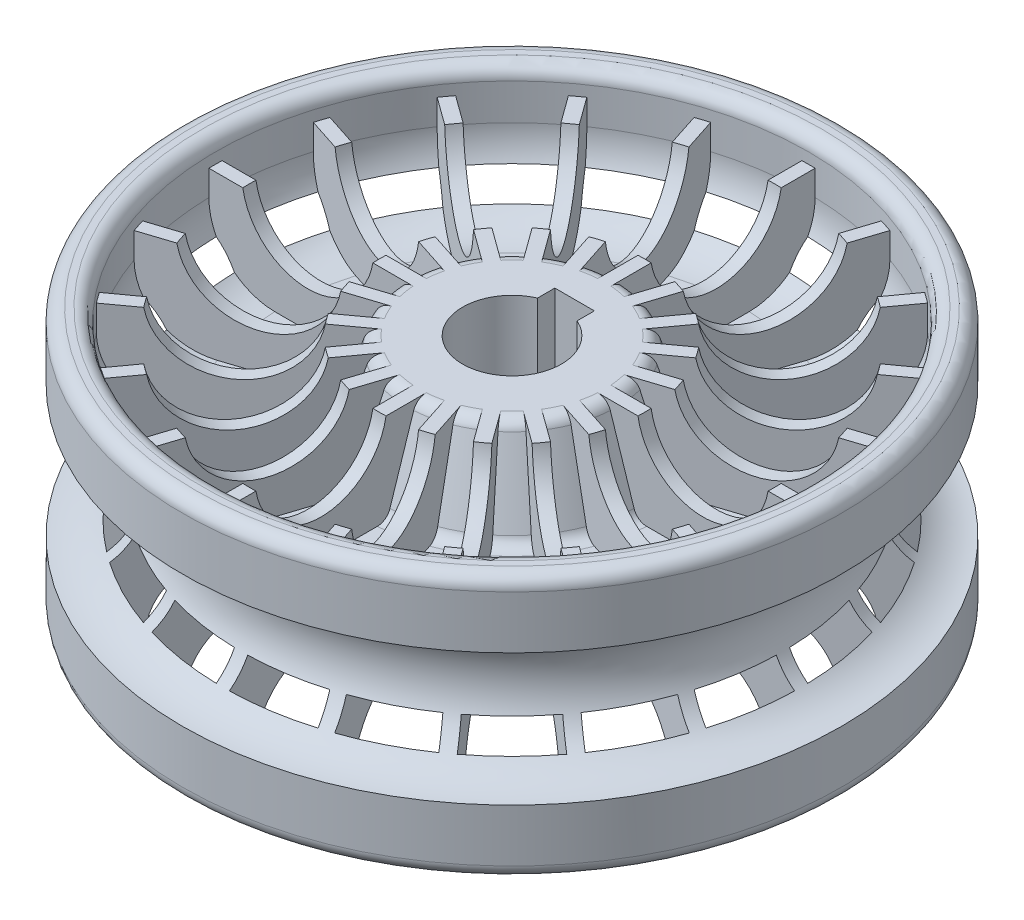
from build123d import *

# Parameters (mm, degrees)
FILLET1_R                    = 1
FILLET2_R                    = 5
RIB5_REACH                   = 41.753
SKETCH2_WALLS_W              = 1
SKETCH2_WALLS_H              = 88.280008708
CIRPATTERN1_COUNT            = 20
CIRPATTERN1_COPY_1_REACH     = 41.753
CIRPATTERN1_COPY_1_SKETCH_W  = 1
CIRPATTERN1_COPY_1_SKETCH_H  = 88.280008708
CIRPATTERN1_COPY_2_REACH     = 41.753
CIRPATTERN1_COPY_2_SKETCH_W  = 1
CIRPATTERN1_COPY_2_SKETCH_H  = 88.280008708
CIRPATTERN1_COPY_3_REACH     = 41.753
CIRPATTERN1_COPY_3_SKETCH_W  = 1
CIRPATTERN1_COPY_3_SKETCH_H  = 88.280008708
CIRPATTERN1_COPY_4_REACH     = 41.753
CIRPATTERN1_COPY_4_SKETCH_W  = 1
CIRPATTERN1_COPY_4_SKETCH_H  = 88.280008708
CIRPATTERN1_COPY_5_REACH     = 41.753
CIRPATTERN1_COPY_5_SKETCH_W  = 1
CIRPATTERN1_COPY_5_SKETCH_H  = 88.280008708
CIRPATTERN1_COPY_6_REACH     = 41.753
CIRPATTERN1_COPY_6_SKETCH_W  = 1
CIRPATTERN1_COPY_6_SKETCH_H  = 88.280008708
CIRPATTERN1_COPY_7_REACH     = 41.753
CIRPATTERN1_COPY_7_SKETCH_W  = 1
CIRPATTERN1_COPY_7_SKETCH_H  = 88.280008708
CIRPATTERN1_COPY_8_REACH     = 41.753
CIRPATTERN1_COPY_8_SKETCH_W  = 1
CIRPATTERN1_COPY_8_SKETCH_H  = 88.280008708
CIRPATTERN1_COPY_9_REACH     = 41.753
CIRPATTERN1_COPY_9_SKETCH_W  = 1
CIRPATTERN1_COPY_9_SKETCH_H  = 88.280008708
CIRPATTERN1_COPY_10_REACH    = 41.753
CIRPATTERN1_COPY_10_SKETCH_W = 1
CIRPATTERN1_COPY_10_SKETCH_H = 88.280008708
CIRPATTERN1_COPY_11_REACH    = 41.753
CIRPATTERN1_COPY_11_SKETCH_W = 1
CIRPATTERN1_COPY_11_SKETCH_H = 88.280008708
CIRPATTERN1_COPY_12_REACH    = 41.753
CIRPATTERN1_COPY_12_SKETCH_W = 1
CIRPATTERN1_COPY_12_SKETCH_H = 88.280008708
CIRPATTERN1_COPY_13_REACH    = 41.753
CIRPATTERN1_COPY_13_SKETCH_W = 1
CIRPATTERN1_COPY_13_SKETCH_H = 88.280008708
CIRPATTERN1_COPY_14_REACH    = 41.753
CIRPATTERN1_COPY_14_SKETCH_W = 1
CIRPATTERN1_COPY_14_SKETCH_H = 88.280008708
CIRPATTERN1_COPY_15_REACH    = 41.753
CIRPATTERN1_COPY_15_SKETCH_W = 1
CIRPATTERN1_COPY_15_SKETCH_H = 88.280008708
CIRPATTERN1_COPY_16_REACH    = 41.753
CIRPATTERN1_COPY_16_SKETCH_W = 1
CIRPATTERN1_COPY_16_SKETCH_H = 88.280008708
CIRPATTERN1_COPY_17_REACH    = 41.753
CIRPATTERN1_COPY_17_SKETCH_W = 1
CIRPATTERN1_COPY_17_SKETCH_H = 88.280008708
CIRPATTERN1_COPY_18_REACH    = 41.753
CIRPATTERN1_COPY_18_SKETCH_W = 1
CIRPATTERN1_COPY_18_SKETCH_H = 88.280008708
CIRPATTERN1_COPY_19_REACH    = 41.753
CIRPATTERN1_COPY_19_SKETCH_W = 1
CIRPATTERN1_COPY_19_SKETCH_H = 88.280008708
SKETCH3_R                    = 5
SKETCH4_W                    = 3
SKETCH4_H                    = 2
CUT_EXTRUDE2_DEPTH           = 40.753275681
CUT_EXTRUDE2_DEPTH_BACK      = 40.753275681


with BuildPart() as part:
    # Sketch1 → Revolve1 (revolve)
    with BuildSketch(Plane.XY, mode=Mode.PRIVATE) as revolve1_sk:
        Polygon((-3.75, -8.174787959), (-3.75, 8.174787959), (-7.75, 8.174787959), (-10, 1.25), (-22.5, 1.25), (-22.5, 10), (-25, 10), (-25, -10), (-22.5, -10), (-22.5, -1.25), (-10, -1.25), (-7.75, -8.174787959), align=None)
    revolve(revolve1_sk.sketch.rotate(Axis((0, 0, 0), (0, 1, 0)), 270), axis=Axis((0, 0, 0), (0, 1, 0)))

    # Fillet1
    fillet1_edges = [part.edges().sort_by_distance(p)[0] for p in [
        (0, -10, 22.5),
        (0, -10, 25),
        (0, 10, 25),
        (0, 10, 22.5),
        (0, 1.25, 10),
        (0, 8.174787959, 7.75),
        (0, -8.174787959, 7.75),
        (0, -1.25, 10),
    ]]
    fillet(fillet1_edges, radius=FILLET1_R)

    # Fillet2
    fillet2_edges = [part.edges().sort_by_distance(p)[0] for p in [
        (0, 1.25, 22.5),
        (0, -1.25, 22.5),
    ]]
    fillet(fillet2_edges, radius=FILLET2_R)

    # Sketch2 walls → Rib5 (add, up to next)
    with BuildSketch(Plane(origin=(0, 8.174787959, 0), x_dir=(1, 0, 0), z_dir=(0, 1, 0)), mode=Mode.PRIVATE) as rib5_sk1:
        with Locations((0, 14.113271264)):
            Rectangle(SKETCH2_WALLS_W, SKETCH2_WALLS_H)
    rib5_tool1 = extrude(rib5_sk1.sketch, amount=-RIB5_REACH, mode=Mode.PRIVATE) - part.part
    rib5 = rib5_tool1.solids().sort_by_distance((0, 8.174787959, -14.113271264))[0]
    add(rib5)

    # Mirror1: Rib5 across plane
    add(rib5.mirror(Plane.ZX))

    # CirPattern1: Rib5 ×20 about axis
    cirpattern1_axis = Axis((0, 0, 0), (0, 1, 0))
    for i in range(1, CIRPATTERN1_COUNT):
        add(rib5.rotate(cirpattern1_axis, i * 360 / CIRPATTERN1_COUNT))

    # CirPattern1 copy 1 sketch → CirPattern1 copy 1 (add, up to next)
    with BuildSketch(Plane(origin=(0, -8.174787959, 0), x_dir=(0.9510565162951535, 0, -0.3090169943749474), z_dir=(0, -1, 0)), mode=Mode.PRIVATE) as cirpattern1_copy_1_sk1:
        with Locations((0, -14.113271264)):
            Rectangle(CIRPATTERN1_COPY_1_SKETCH_W, CIRPATTERN1_COPY_1_SKETCH_H)
    cirpattern1_copy_1_tool1 = extrude(cirpattern1_copy_1_sk1.sketch, amount=-CIRPATTERN1_COPY_1_REACH, mode=Mode.PRIVATE) - part.part
    add(cirpattern1_copy_1_tool1.solids().sort_by_distance((-4.361240667, -8.174787959, -13.422518602))[0])

    # CirPattern1 copy 2 sketch → CirPattern1 copy 2 (add, up to next)
    with BuildSketch(Plane(origin=(0, -8.174787959, 0), x_dir=(0.8090169943749475, 0, -0.5877852522924731), z_dir=(0, -1, 0)), mode=Mode.PRIVATE) as cirpattern1_copy_2_sk1:
        with Locations((0, -14.113271264)):
            Rectangle(CIRPATTERN1_COPY_2_SKETCH_W, CIRPATTERN1_COPY_2_SKETCH_H)
    cirpattern1_copy_2_tool1 = extrude(cirpattern1_copy_2_sk1.sketch, amount=-CIRPATTERN1_COPY_2_REACH, mode=Mode.PRIVATE) - part.part
    add(cirpattern1_copy_2_tool1.solids().sort_by_distance((-8.295572711, -8.174787959, -11.417876299))[0])

    # CirPattern1 copy 3 sketch → CirPattern1 copy 3 (add, up to next)
    with BuildSketch(Plane(origin=(0, -8.174787959, 0), x_dir=(0.5877852522924731, 0, -0.8090169943749475), z_dir=(0, -1, 0)), mode=Mode.PRIVATE) as cirpattern1_copy_3_sk1:
        with Locations((0, -14.113271264)):
            Rectangle(CIRPATTERN1_COPY_3_SKETCH_W, CIRPATTERN1_COPY_3_SKETCH_H)
    cirpattern1_copy_3_tool1 = extrude(cirpattern1_copy_3_sk1.sketch, amount=-CIRPATTERN1_COPY_3_REACH, mode=Mode.PRIVATE) - part.part
    add(cirpattern1_copy_3_tool1.solids().sort_by_distance((-11.417876299, -8.174787959, -8.295572711))[0])

    # CirPattern1 copy 4 sketch → CirPattern1 copy 4 (add, up to next)
    with BuildSketch(Plane(origin=(0, -8.174787959, 0), x_dir=(0.30901699437494745, 0, -0.9510565162951535), z_dir=(0, -1, 0)), mode=Mode.PRIVATE) as cirpattern1_copy_4_sk1:
        with Locations((0, -14.113271264)):
            Rectangle(CIRPATTERN1_COPY_4_SKETCH_W, CIRPATTERN1_COPY_4_SKETCH_H)
    cirpattern1_copy_4_tool1 = extrude(cirpattern1_copy_4_sk1.sketch, amount=-CIRPATTERN1_COPY_4_REACH, mode=Mode.PRIVATE) - part.part
    add(cirpattern1_copy_4_tool1.solids().sort_by_distance((-13.422518602, -8.174787959, -4.361240667))[0])

    # CirPattern1 copy 5 sketch → CirPattern1 copy 5 (add, up to next)
    with BuildSketch(Plane(origin=(0, -8.174787959, 0), x_dir=(0, 0, -1), z_dir=(0, -1, 0)), mode=Mode.PRIVATE) as cirpattern1_copy_5_sk1:
        with Locations((0, -14.113271264)):
            Rectangle(CIRPATTERN1_COPY_5_SKETCH_W, CIRPATTERN1_COPY_5_SKETCH_H)
    cirpattern1_copy_5_tool1 = extrude(cirpattern1_copy_5_sk1.sketch, amount=-CIRPATTERN1_COPY_5_REACH, mode=Mode.PRIVATE) - part.part
    add(cirpattern1_copy_5_tool1.solids().sort_by_distance((-14.113271264, -8.174787959, 0))[0])

    # CirPattern1 copy 6 sketch → CirPattern1 copy 6 (add, up to next)
    with BuildSketch(Plane(origin=(0, -8.174787959, 0), x_dir=(-0.30901699437494734, 0, -0.9510565162951536), z_dir=(0, -1, 0)), mode=Mode.PRIVATE) as cirpattern1_copy_6_sk1:
        with Locations((0, -14.113271264)):
            Rectangle(CIRPATTERN1_COPY_6_SKETCH_W, CIRPATTERN1_COPY_6_SKETCH_H)
    cirpattern1_copy_6_tool1 = extrude(cirpattern1_copy_6_sk1.sketch, amount=-CIRPATTERN1_COPY_6_REACH, mode=Mode.PRIVATE) - part.part
    add(cirpattern1_copy_6_tool1.solids().sort_by_distance((-13.422518602, -8.174787959, 4.361240667))[0])

    # CirPattern1 copy 7 sketch → CirPattern1 copy 7 (add, up to next)
    with BuildSketch(Plane(origin=(0, -8.174787959, 0), x_dir=(-0.587785252292473, 0, -0.8090169943749475), z_dir=(0, -1, 0)), mode=Mode.PRIVATE) as cirpattern1_copy_7_sk1:
        with Locations((0, -14.113271264)):
            Rectangle(CIRPATTERN1_COPY_7_SKETCH_W, CIRPATTERN1_COPY_7_SKETCH_H)
    cirpattern1_copy_7_tool1 = extrude(cirpattern1_copy_7_sk1.sketch, amount=-CIRPATTERN1_COPY_7_REACH, mode=Mode.PRIVATE) - part.part
    add(cirpattern1_copy_7_tool1.solids().sort_by_distance((-11.417876299, -8.174787959, 8.295572711))[0])

    # CirPattern1 copy 8 sketch → CirPattern1 copy 8 (add, up to next)
    with BuildSketch(Plane(origin=(0, -8.174787959, 0), x_dir=(-0.8090169943749473, 0, -0.5877852522924732), z_dir=(0, -1, 0)), mode=Mode.PRIVATE) as cirpattern1_copy_8_sk1:
        with Locations((0, -14.113271264)):
            Rectangle(CIRPATTERN1_COPY_8_SKETCH_W, CIRPATTERN1_COPY_8_SKETCH_H)
    cirpattern1_copy_8_tool1 = extrude(cirpattern1_copy_8_sk1.sketch, amount=-CIRPATTERN1_COPY_8_REACH, mode=Mode.PRIVATE) - part.part
    add(cirpattern1_copy_8_tool1.solids().sort_by_distance((-8.295572711, -8.174787959, 11.417876299))[0])

    # CirPattern1 copy 9 sketch → CirPattern1 copy 9 (add, up to next)
    with BuildSketch(Plane(origin=(0, -8.174787959, 0), x_dir=(-0.9510565162951535, 0, -0.3090169943749475), z_dir=(0, -1, 0)), mode=Mode.PRIVATE) as cirpattern1_copy_9_sk1:
        with Locations((0, -14.113271264)):
            Rectangle(CIRPATTERN1_COPY_9_SKETCH_W, CIRPATTERN1_COPY_9_SKETCH_H)
    cirpattern1_copy_9_tool1 = extrude(cirpattern1_copy_9_sk1.sketch, amount=-CIRPATTERN1_COPY_9_REACH, mode=Mode.PRIVATE) - part.part
    add(cirpattern1_copy_9_tool1.solids().sort_by_distance((-4.361240667, -8.174787959, 13.422518602))[0])

    # CirPattern1 copy 10 sketch → CirPattern1 copy 10 (add, up to next)
    with BuildSketch(Plane(origin=(0, -8.174787959, 0), x_dir=(-1, 0, 0), z_dir=(0, -1, 0)), mode=Mode.PRIVATE) as cirpattern1_copy_10_sk1:
        with Locations((0, -14.113271264)):
            Rectangle(CIRPATTERN1_COPY_10_SKETCH_W, CIRPATTERN1_COPY_10_SKETCH_H)
    cirpattern1_copy_10_tool1 = extrude(cirpattern1_copy_10_sk1.sketch, amount=-CIRPATTERN1_COPY_10_REACH, mode=Mode.PRIVATE) - part.part
    add(cirpattern1_copy_10_tool1.solids().sort_by_distance((0, -8.174787959, 14.113271264))[0])

    # CirPattern1 copy 11 sketch → CirPattern1 copy 11 (add, up to next)
    with BuildSketch(Plane(origin=(0, -8.174787959, 0), x_dir=(-0.9510565162951536, 0, 0.3090169943749473), z_dir=(0, -1, 0)), mode=Mode.PRIVATE) as cirpattern1_copy_11_sk1:
        with Locations((0, -14.113271264)):
            Rectangle(CIRPATTERN1_COPY_11_SKETCH_W, CIRPATTERN1_COPY_11_SKETCH_H)
    cirpattern1_copy_11_tool1 = extrude(cirpattern1_copy_11_sk1.sketch, amount=-CIRPATTERN1_COPY_11_REACH, mode=Mode.PRIVATE) - part.part
    add(cirpattern1_copy_11_tool1.solids().sort_by_distance((4.361240667, -8.174787959, 13.422518602))[0])

    # CirPattern1 copy 12 sketch → CirPattern1 copy 12 (add, up to next)
    with BuildSketch(Plane(origin=(0, -8.174787959, 0), x_dir=(-0.8090169943749476, 0, 0.587785252292473), z_dir=(0, -1, 0)), mode=Mode.PRIVATE) as cirpattern1_copy_12_sk1:
        with Locations((0, -14.113271264)):
            Rectangle(CIRPATTERN1_COPY_12_SKETCH_W, CIRPATTERN1_COPY_12_SKETCH_H)
    cirpattern1_copy_12_tool1 = extrude(cirpattern1_copy_12_sk1.sketch, amount=-CIRPATTERN1_COPY_12_REACH, mode=Mode.PRIVATE) - part.part
    add(cirpattern1_copy_12_tool1.solids().sort_by_distance((8.295572711, -8.174787959, 11.417876299))[0])

    # CirPattern1 copy 13 sketch → CirPattern1 copy 13 (add, up to next)
    with BuildSketch(Plane(origin=(0, -8.174787959, 0), x_dir=(-0.5877852522924732, 0, 0.8090169943749473), z_dir=(0, -1, 0)), mode=Mode.PRIVATE) as cirpattern1_copy_13_sk1:
        with Locations((0, -14.113271264)):
            Rectangle(CIRPATTERN1_COPY_13_SKETCH_W, CIRPATTERN1_COPY_13_SKETCH_H)
    cirpattern1_copy_13_tool1 = extrude(cirpattern1_copy_13_sk1.sketch, amount=-CIRPATTERN1_COPY_13_REACH, mode=Mode.PRIVATE) - part.part
    add(cirpattern1_copy_13_tool1.solids().sort_by_distance((11.417876299, -8.174787959, 8.295572711))[0])

    # CirPattern1 copy 14 sketch → CirPattern1 copy 14 (add, up to next)
    with BuildSketch(Plane(origin=(0, -8.174787959, 0), x_dir=(-0.30901699437494756, 0, 0.9510565162951535), z_dir=(0, -1, 0)), mode=Mode.PRIVATE) as cirpattern1_copy_14_sk1:
        with Locations((0, -14.113271264)):
            Rectangle(CIRPATTERN1_COPY_14_SKETCH_W, CIRPATTERN1_COPY_14_SKETCH_H)
    cirpattern1_copy_14_tool1 = extrude(cirpattern1_copy_14_sk1.sketch, amount=-CIRPATTERN1_COPY_14_REACH, mode=Mode.PRIVATE) - part.part
    add(cirpattern1_copy_14_tool1.solids().sort_by_distance((13.422518602, -8.174787959, 4.361240667))[0])

    # CirPattern1 copy 15 sketch → CirPattern1 copy 15 (add, up to next)
    with BuildSketch(Plane(origin=(0, -8.174787959, 0), x_dir=(0, 0, 1), z_dir=(0, -1, 0)), mode=Mode.PRIVATE) as cirpattern1_copy_15_sk1:
        with Locations((0, -14.113271264)):
            Rectangle(CIRPATTERN1_COPY_15_SKETCH_W, CIRPATTERN1_COPY_15_SKETCH_H)
    cirpattern1_copy_15_tool1 = extrude(cirpattern1_copy_15_sk1.sketch, amount=-CIRPATTERN1_COPY_15_REACH, mode=Mode.PRIVATE) - part.part
    add(cirpattern1_copy_15_tool1.solids().sort_by_distance((14.113271264, -8.174787959, 0))[0])

    # CirPattern1 copy 16 sketch → CirPattern1 copy 16 (add, up to next)
    with BuildSketch(Plane(origin=(0, -8.174787959, 0), x_dir=(0.30901699437494723, 0, 0.9510565162951536), z_dir=(0, -1, 0)), mode=Mode.PRIVATE) as cirpattern1_copy_16_sk1:
        with Locations((0, -14.113271264)):
            Rectangle(CIRPATTERN1_COPY_16_SKETCH_W, CIRPATTERN1_COPY_16_SKETCH_H)
    cirpattern1_copy_16_tool1 = extrude(cirpattern1_copy_16_sk1.sketch, amount=-CIRPATTERN1_COPY_16_REACH, mode=Mode.PRIVATE) - part.part
    add(cirpattern1_copy_16_tool1.solids().sort_by_distance((13.422518602, -8.174787959, -4.361240667))[0])

    # CirPattern1 copy 17 sketch → CirPattern1 copy 17 (add, up to next)
    with BuildSketch(Plane(origin=(0, -8.174787959, 0), x_dir=(0.5877852522924729, 0, 0.8090169943749476), z_dir=(0, -1, 0)), mode=Mode.PRIVATE) as cirpattern1_copy_17_sk1:
        with Locations((0, -14.113271264)):
            Rectangle(CIRPATTERN1_COPY_17_SKETCH_W, CIRPATTERN1_COPY_17_SKETCH_H)
    cirpattern1_copy_17_tool1 = extrude(cirpattern1_copy_17_sk1.sketch, amount=-CIRPATTERN1_COPY_17_REACH, mode=Mode.PRIVATE) - part.part
    add(cirpattern1_copy_17_tool1.solids().sort_by_distance((11.417876299, -8.174787959, -8.295572711))[0])

    # CirPattern1 copy 18 sketch → CirPattern1 copy 18 (add, up to next)
    with BuildSketch(Plane(origin=(0, -8.174787959, 0), x_dir=(0.8090169943749473, 0, 0.5877852522924734), z_dir=(0, -1, 0)), mode=Mode.PRIVATE) as cirpattern1_copy_18_sk1:
        with Locations((0, -14.113271264)):
            Rectangle(CIRPATTERN1_COPY_18_SKETCH_W, CIRPATTERN1_COPY_18_SKETCH_H)
    cirpattern1_copy_18_tool1 = extrude(cirpattern1_copy_18_sk1.sketch, amount=-CIRPATTERN1_COPY_18_REACH, mode=Mode.PRIVATE) - part.part
    add(cirpattern1_copy_18_tool1.solids().sort_by_distance((8.295572711, -8.174787959, -11.417876299))[0])

    # CirPattern1 copy 19 sketch → CirPattern1 copy 19 (add, up to next)
    with BuildSketch(Plane(origin=(0, -8.174787959, 0), x_dir=(0.9510565162951535, 0, 0.3090169943749476), z_dir=(0, -1, 0)), mode=Mode.PRIVATE) as cirpattern1_copy_19_sk1:
        with Locations((0, -14.113271264)):
            Rectangle(CIRPATTERN1_COPY_19_SKETCH_W, CIRPATTERN1_COPY_19_SKETCH_H)
    cirpattern1_copy_19_tool1 = extrude(cirpattern1_copy_19_sk1.sketch, amount=-CIRPATTERN1_COPY_19_REACH, mode=Mode.PRIVATE) - part.part
    add(cirpattern1_copy_19_tool1.solids().sort_by_distance((4.361240667, -8.174787959, -13.422518602))[0])

    # Sketch3 → Cut-Revolve1 (revolve, cut)
    with BuildSketch(Plane.XY, mode=Mode.PRIVATE) as cut_revolve1_sk:
        with Locations((-25, 0)):
            Circle(SKETCH3_R)
        with Locations((-15, 9)):
            Circle(SKETCH3_R)
        with Locations((-15, -9)):
            Circle(SKETCH3_R)
    revolve(cut_revolve1_sk.sketch.rotate(Axis((0, 0, 0), (0, 1, 0)), 271.273344361), axis=Axis((0, 0, 0), (0, 1, 0)), mode=Mode.SUBTRACT)

    # Sketch4 → Cut-Extrude2 (cut, two sides)
    with BuildSketch(Plane(origin=(0, 8.174787959, 0), x_dir=(1, 0, 0), z_dir=(0, 1, 0))) as cut_extrude2_sk:
        with Locations((0, 3.75)):
            Rectangle(SKETCH4_W, SKETCH4_H)
    extrude(amount=CUT_EXTRUDE2_DEPTH, mode=Mode.SUBTRACT)
    extrude(cut_extrude2_sk.sketch, amount=-CUT_EXTRUDE2_DEPTH_BACK, mode=Mode.SUBTRACT)


solid = part.part
